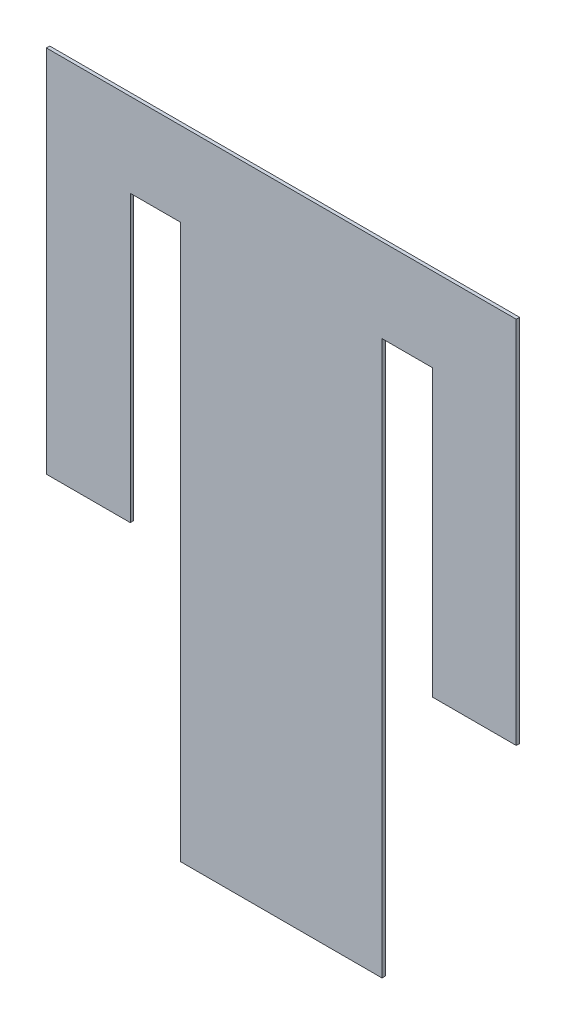
from build123d import *

# Parameters (mm, degrees)
BOSS_EXTRUDE1_DEPTH = 2


with BuildPart() as part:
    # Sketch1 → Boss-Extrude1 (new body)
    with BuildSketch(Plane.XY):
        Polygon((0, 0), (0, 220), (280, 220), (280, 0), (230, 0), (230, 170), (200, 170), (200, -160), (80, -160), (80, 170), (50, 170), (50, 0), align=None)
    extrude(amount=BOSS_EXTRUDE1_DEPTH)


solid = part.part
